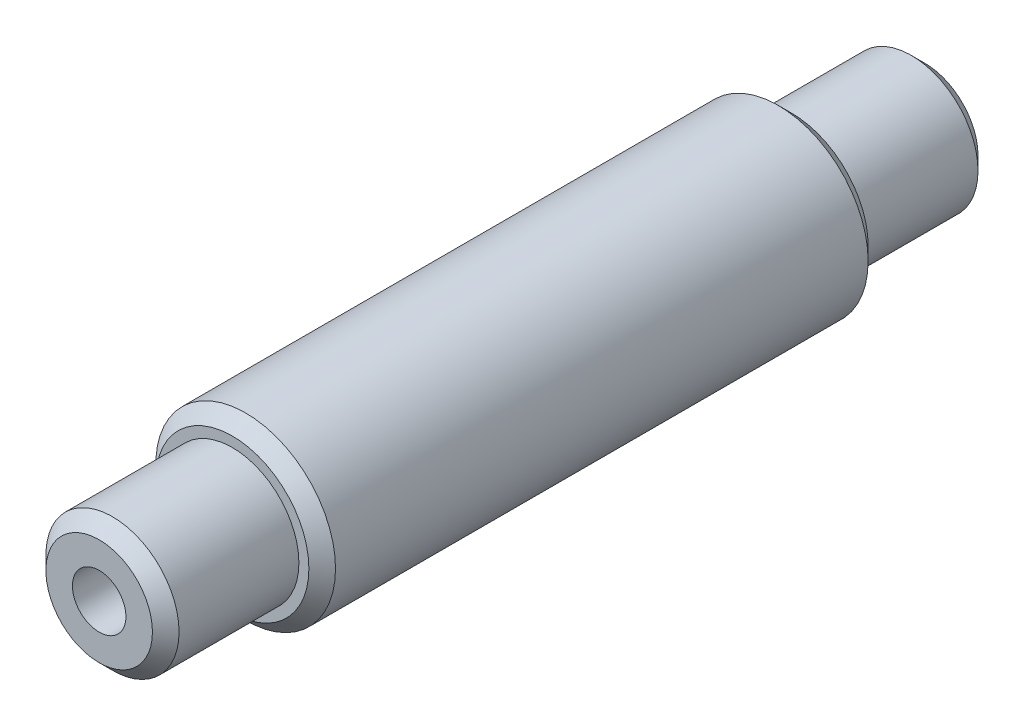
from build123d import *

# Parameters (mm, degrees)
SKETCH1_R                   = 8.5725
SKETCH1_R_2                 = 6.35
BOSS_EXTRUDE1_DEPTH         = 26.67
SKETCH2_R                   = 6.35
BOSS_EXTRUDE2_DEPTH         = 39.37
CHAMFER1_SIZE               = 1.27
F_1_4_20_TAPPED_HOLE1_D     = 5.1054
F_1_4_20_TAPPED_HOLE1_DEPTH = 25.4
F_1_4_20_TAPPED_HOLE1_TIP   = 1.533816902
F_1_4_20_TAPPED_HOLE2_D     = 5.1054
F_1_4_20_TAPPED_HOLE2_DEPTH = 25.4
F_1_4_20_TAPPED_HOLE2_TIP   = 1.533816902


with BuildPart() as part:
    # Sketch1 → Boss-Extrude1 (new body, symmetric)
    with BuildSketch(Plane.XY):
        Circle(SKETCH1_R)
        Circle(SKETCH1_R_2, mode=Mode.SUBTRACT)
    extrude(amount=BOSS_EXTRUDE1_DEPTH, both=True)

    # Sketch2 → Boss-Extrude2 (add, symmetric)
    with BuildSketch(Plane.XY):
        Circle(SKETCH2_R)
    extrude(amount=BOSS_EXTRUDE2_DEPTH, both=True)

    # Chamfer1
    chamfer1_edges = [part.edges().sort_by_distance(p)[0] for p in [
        (-8.5725, 0, -26.67),
        (-8.5725, 0, 26.67),
        (-6.35, 0, -39.37),
        (-6.35, 0, 39.37),
    ]]
    chamfer(chamfer1_edges, length=CHAMFER1_SIZE)

    # 1/4-20 Tapped Hole1
    with Locations(Plane(origin=(0, 0, -39.37), x_dir=(-1, 0, 0), z_dir=(0, 0, -1))):
        with Locations((0, 0)):
            Hole(F_1_4_20_TAPPED_HOLE1_D / 2, depth=F_1_4_20_TAPPED_HOLE1_DEPTH)
            with Locations((0, 0, -(F_1_4_20_TAPPED_HOLE1_DEPTH + F_1_4_20_TAPPED_HOLE1_TIP / 2))):  # 118° drill point
                Cone(0, F_1_4_20_TAPPED_HOLE1_D / 2, F_1_4_20_TAPPED_HOLE1_TIP, mode=Mode.SUBTRACT)

    # 1/4-20 Tapped Hole2
    with Locations(Plane.XY.offset(39.37)):
        with Locations((0, 0)):
            Hole(F_1_4_20_TAPPED_HOLE2_D / 2, depth=F_1_4_20_TAPPED_HOLE2_DEPTH)
            with Locations((0, 0, -(F_1_4_20_TAPPED_HOLE2_DEPTH + F_1_4_20_TAPPED_HOLE2_TIP / 2))):  # 118° drill point
                Cone(0, F_1_4_20_TAPPED_HOLE2_D / 2, F_1_4_20_TAPPED_HOLE2_TIP, mode=Mode.SUBTRACT)


solid = part.part
